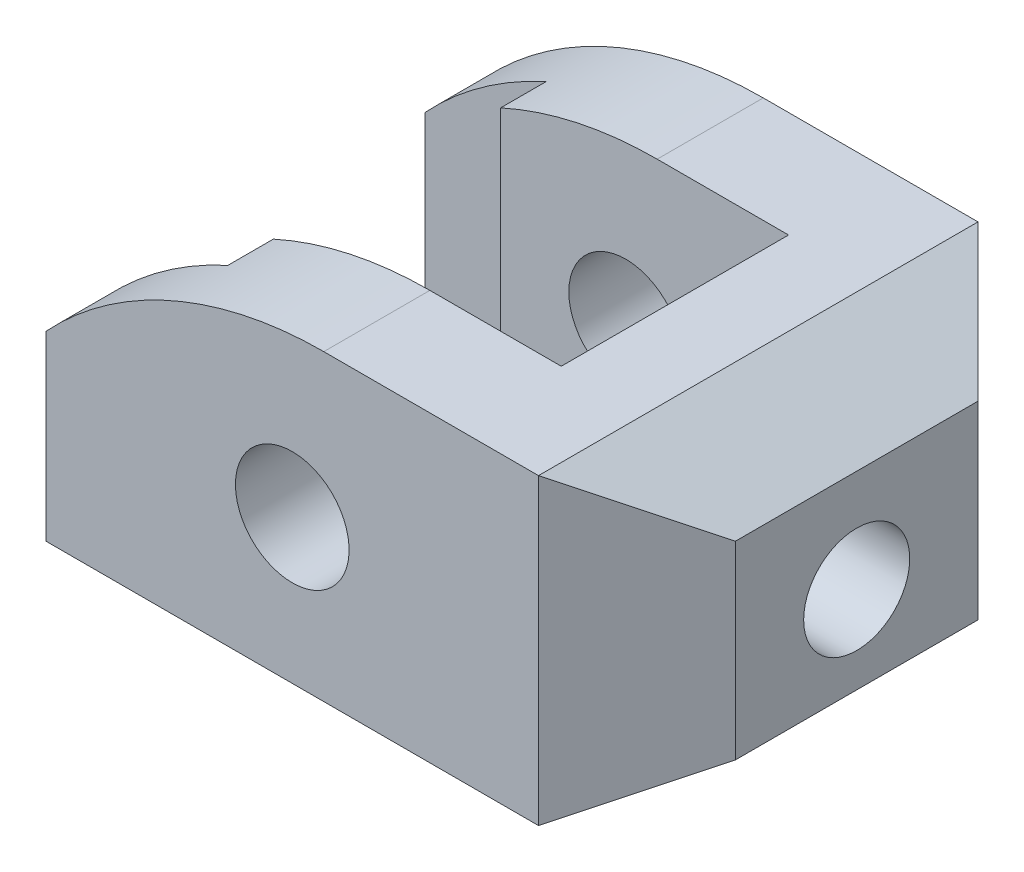
from build123d import *

# Parameters (mm, degrees)
SKETCH1_R               = 7.5
BOSS_EXTRUDE1_DEPTH     = 58
SKETCH2_W               = 38
SKETCH2_H               = 30
CUT_EXTRUDE1_DEPTH      = 84.865217872
CUT_EXTRUDE1_DEPTH_BACK = 84.865217872
SKETCH3_W               = 16
SKETCH3_H               = 6
CUT_EXTRUDE4_DEPTH      = 84.865217872
CUT_EXTRUDE4_DEPTH_BACK = 84.865217872
SKETCH4_R               = 7
CUT_EXTRUDE5_DEPTH      = 100.435906681
CUT_EXTRUDE5_DEPTH_BACK = 100.435906681
CUT_EXTRUDE6_DEPTH      = 84.865217872
CUT_EXTRUDE6_DEPTH_BACK = 84.865217872


with BuildPart() as part:
    # Sketch1 → Boss-Extrude1 (new body)
    with BuildSketch(Plane.XY):
        with BuildLine():
            Line((32.5, -19), (-32.5, -19))
            Line((-32.5, -19), (-32.5, 5))
            ThreePointArc((-32.5, 5), (-15.83939444, 16.82575695), (4.16060556, 21))
            Line((4.16060556, 21), (32.5, 21))
            Line((32.5, 21), (45.490381057, 13.5))
            Line((45.490381057, 13.5), (45.490381057, -11.5))
            Line((45.490381057, -11.5), (32.5, -19))
        make_face()
        with Locations(Location((0, 0, 0), (0, 0, 180))):
            Circle(SKETCH1_R, mode=Mode.SUBTRACT)
    extrude(amount=BOSS_EXTRUDE1_DEPTH)

    # Sketch2 → Cut-Extrude1 (cut, two sides)
    with BuildSketch(Plane(origin=(0, 21, 0), x_dir=(1, 0, 0), z_dir=(0, 1, 0))) as cut_extrude1_sk:
        with Locations((2.5, -29)):
            Rectangle(SKETCH2_W, SKETCH2_H)
    extrude(amount=CUT_EXTRUDE1_DEPTH, mode=Mode.SUBTRACT)
    extrude(cut_extrude1_sk.sketch, amount=-CUT_EXTRUDE1_DEPTH_BACK, mode=Mode.SUBTRACT)

    # Sketch3 → Cut-Extrude4 (cut, two sides)
    with BuildSketch(Plane(origin=(0, 21, 0), x_dir=(1, 0, 0), z_dir=(0, 1, 0))) as cut_extrude4_sk:
        with Locations((-24.5, -47)):
            Rectangle(SKETCH3_W, SKETCH3_H)
        with Locations((-24.5, -11)):
            Rectangle(SKETCH3_W, SKETCH3_H)
    extrude(amount=CUT_EXTRUDE4_DEPTH, mode=Mode.SUBTRACT)
    extrude(cut_extrude4_sk.sketch, amount=-CUT_EXTRUDE4_DEPTH_BACK, mode=Mode.SUBTRACT)


with BuildPart() as body_2:
    # of the pieces the cut leaves, the one that is kept (cut_extrude4_keep)
    add(part.part.solids().sort_by_distance((4.16060556, 21, 0))[0])

    # Sketch4 → Cut-Extrude5 (cut, two sides)
    with BuildSketch(Plane(origin=(45.490381057, 0, 0), x_dir=(0, 0, -1), z_dir=(1, 0, 0))) as cut_extrude5_sk:
        with Locations(Location((-29, 0, 0), (0, 0, 90))):
            Circle(SKETCH4_R)
    extrude(amount=CUT_EXTRUDE5_DEPTH, mode=Mode.SUBTRACT)
    extrude(cut_extrude5_sk.sketch, amount=-CUT_EXTRUDE5_DEPTH_BACK, mode=Mode.SUBTRACT)

    # Sketch6 → Cut-Extrude6 (cut, two sides)
    with BuildSketch(Plane(origin=(0, 21, 0), x_dir=(1, 0, 0), z_dir=(0, 1, 0))) as cut_extrude6_sk:
        Polygon((32.5, 0), (45.490381057, -12.990381057), (45.490381057, 0), align=None)
        Polygon((45.490381057, -45.009618943), (45.490381057, -58), (32.5, -58), align=None)
    extrude(amount=CUT_EXTRUDE6_DEPTH, mode=Mode.SUBTRACT)
    extrude(cut_extrude6_sk.sketch, amount=-CUT_EXTRUDE6_DEPTH_BACK, mode=Mode.SUBTRACT)


solid = body_2.part
